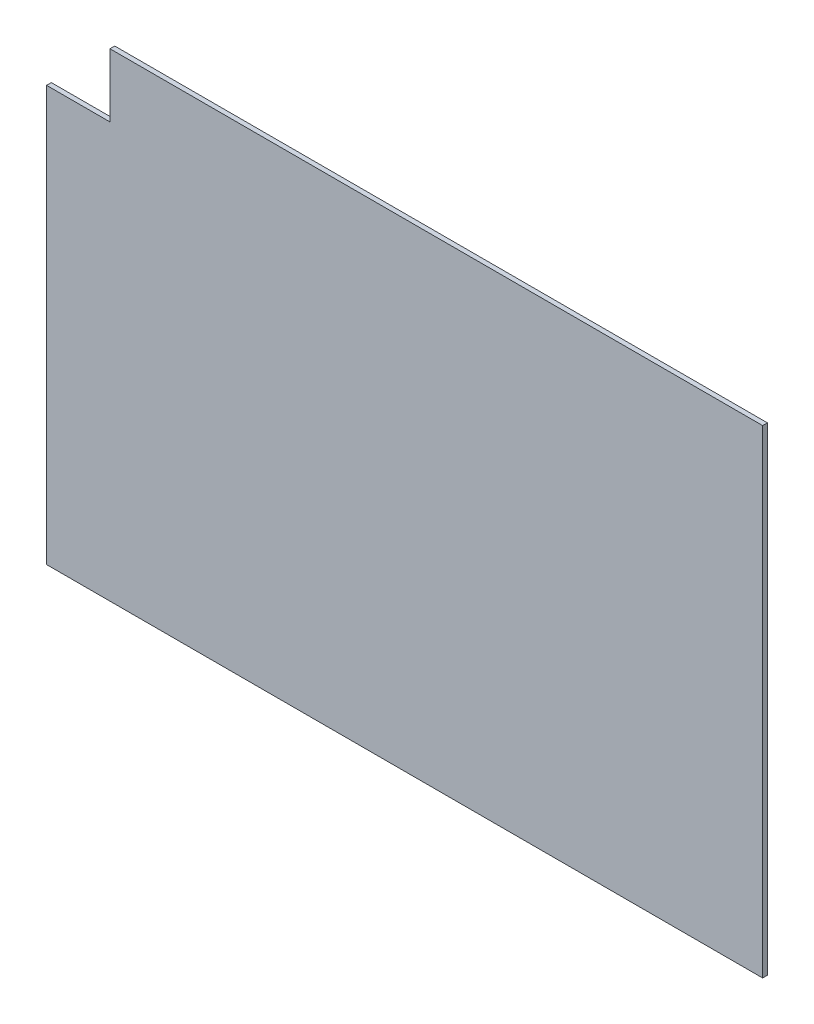
from build123d import *

# Parameters (mm, degrees)
EXTRUDE_1_DEPTH = 1.5


with BuildPart() as part:
    # ｽｹｯﾁ1 → ﾎﾞｽ - 押し出し1 (new body, symmetric)
    with BuildSketch(Plane.XY):
        Polygon((-226, 109.923812784), (-226, -152.076187216), (226, -152.076187216), (226, 149.923812784), (-186, 149.923812784), (-186, 109.923812784), align=None)
    extrude(amount=EXTRUDE_1_DEPTH, both=True)


solid = part.part
